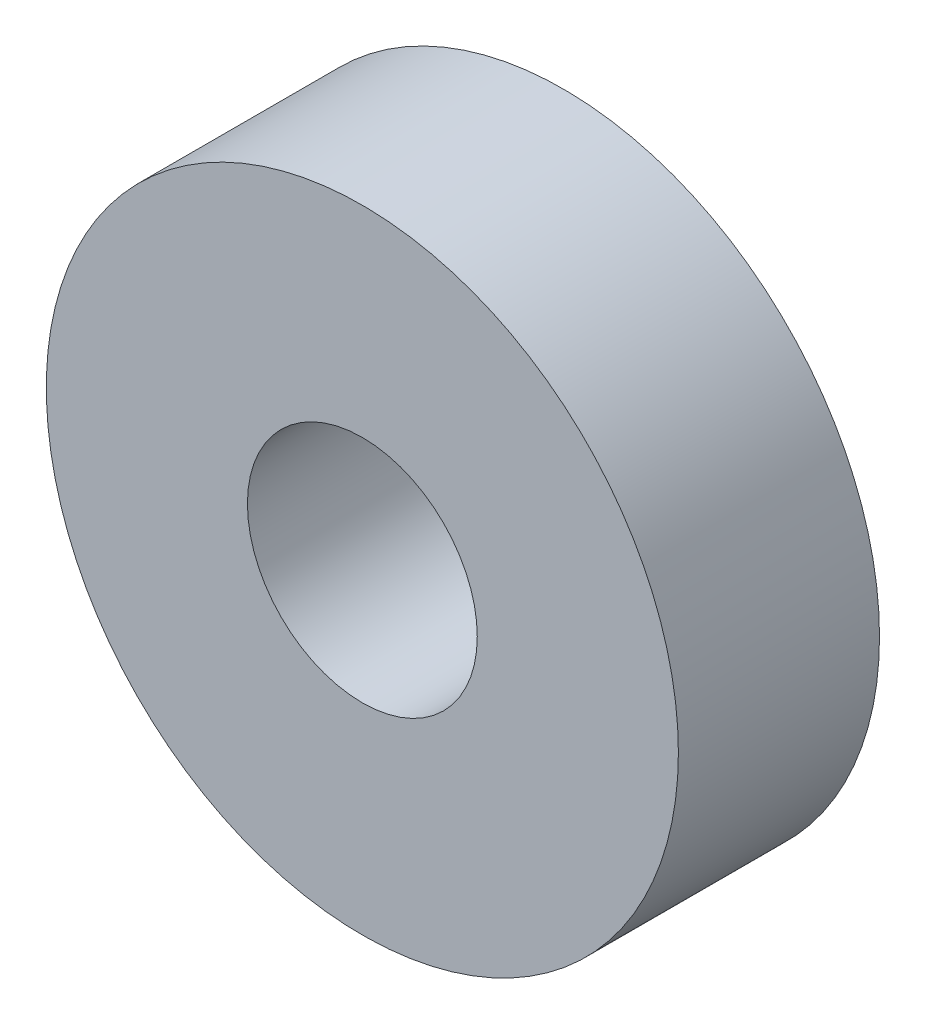
from build123d import *

# Parameters (mm, degrees)
CROQUIS1_R              = 11
CROQUIS1_R_2            = 4
SALIENTE_EXTRUIR1_DEPTH = 7


with BuildPart() as part:
    # Croquis1 → Saliente-Extruir1 (new body)
    with BuildSketch(Plane.XY):
        Circle(CROQUIS1_R)
        Circle(CROQUIS1_R_2, mode=Mode.SUBTRACT)
    extrude(amount=SALIENTE_EXTRUIR1_DEPTH)


solid = part.part
